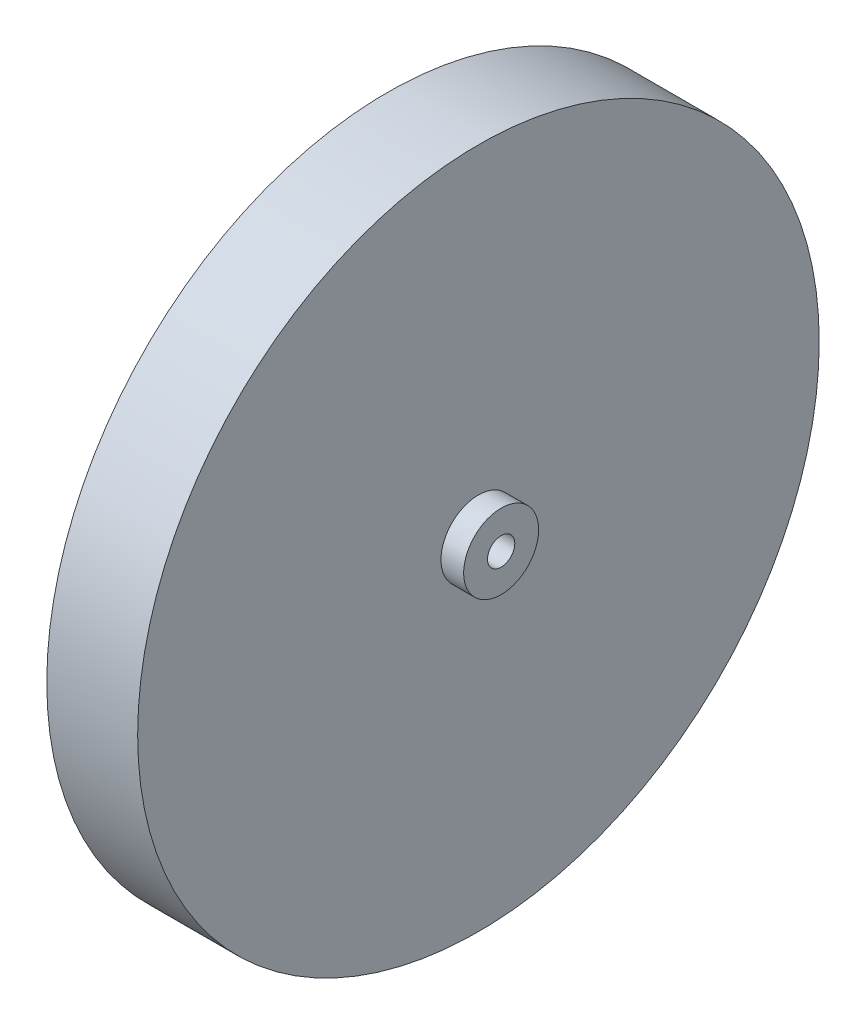
from build123d import *

# Parameters (mm, degrees)
SKETCH1_R           = 38.1
BOSS_EXTRUDE1_DEPTH = 10.16
SKETCH3_R           = 4.191
BOSS_EXTRUDE2_DEPTH = 2.54
SKETCH4_R           = 1.524
CUT_EXTRUDE1_DEPTH  = 13.7
SKETCH5_R           = 22.86
CUT_EXTRUDE2_DEPTH  = 3.81
SKETCH6_R           = 12.7
CUT_EXTRUDE3_DEPTH  = 2.54
SKETCH7_R           = 6.731
BOSS_EXTRUDE3_DEPTH = 3.81
SKETCH9_R           = 3.81
CUT_EXTRUDE4_DEPTH  = 3.81


with BuildPart() as part:
    # Sketch1 → Boss-Extrude1 (new body)
    with BuildSketch(Plane(origin=(0, 0, 0), x_dir=(0, 0, -1), z_dir=(1, 0, 0))):
        Circle(SKETCH1_R)
    extrude(amount=BOSS_EXTRUDE1_DEPTH)

    # Sketch3 → Boss-Extrude2 (add)
    with BuildSketch(Plane(origin=(10.16, 0, 0), x_dir=(0, 0, -1), z_dir=(1, 0, 0))):
        Circle(SKETCH3_R)
    extrude(amount=BOSS_EXTRUDE2_DEPTH)

    # Sketch4 → Cut-Extrude1 (cut, through all)
    with BuildSketch(Plane(origin=(12.7, 0, 0), x_dir=(0, 0, -1), z_dir=(1, 0, 0))):
        Circle(SKETCH4_R)
    extrude(amount=-CUT_EXTRUDE1_DEPTH, mode=Mode.SUBTRACT)

    # Sketch5 → Cut-Extrude2 (cut)
    with BuildSketch(Plane.ZY):
        Circle(SKETCH5_R)
    extrude(amount=-CUT_EXTRUDE2_DEPTH, mode=Mode.SUBTRACT)

    # Sketch6 → Cut-Extrude3 (cut)
    with BuildSketch(Plane.ZY.offset(-3.81)):
        Circle(SKETCH6_R)
    extrude(amount=-CUT_EXTRUDE3_DEPTH, mode=Mode.SUBTRACT)

    # Sketch7 → Boss-Extrude3 (add)
    with BuildSketch(Plane.ZY.offset(-6.35)):
        Circle(SKETCH7_R)
    extrude(amount=BOSS_EXTRUDE3_DEPTH)

    # Sketch9 → Cut-Extrude4 (cut)
    with BuildSketch(Plane.ZY.offset(-2.54)):
        Circle(SKETCH9_R)
    extrude(amount=-CUT_EXTRUDE4_DEPTH, mode=Mode.SUBTRACT)


solid = part.part
